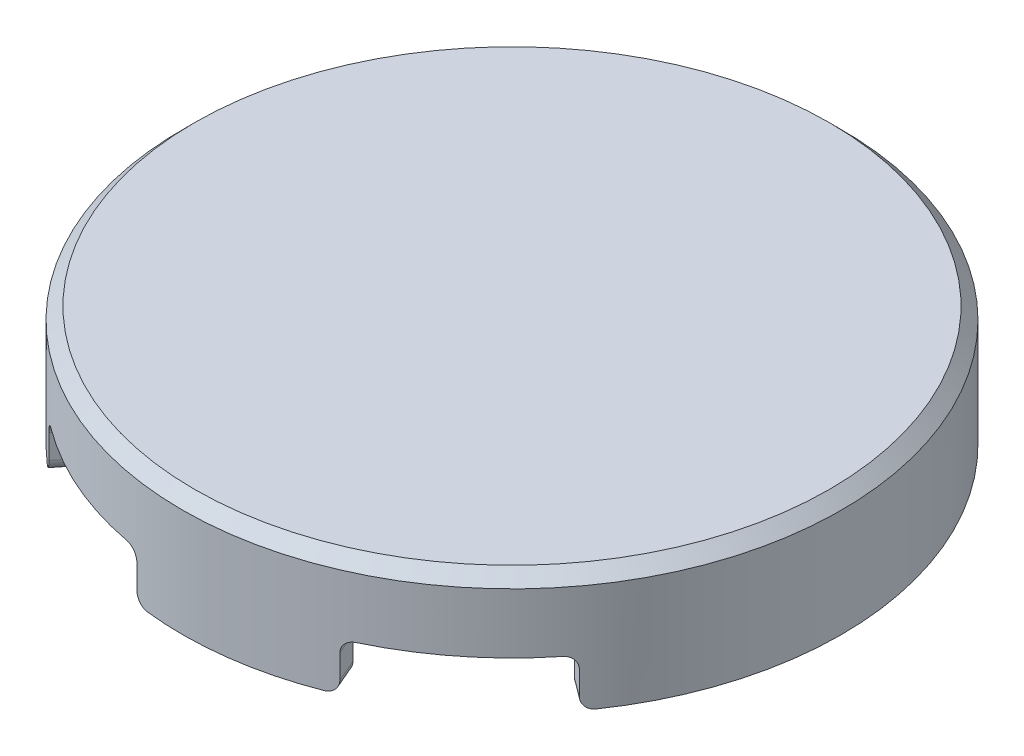
from build123d import *

# Parameters (mm, degrees)
SKETCH1_R           = 13.75
BOSS_EXTRUDE1_DEPTH = 5
SKETCH2_R           = 12.7
CUT_EXTRUDE1_DEPTH  = 3
CHAMFER1_SIZE       = 0.5
CUT_EXTRUDE2_DEPTH  = 2
FILLET1_R           = 0.5


with BuildPart() as part:
    # Sketch1 → Boss-Extrude1 (new body)
    with BuildSketch(Plane(origin=(0, 0, 0), x_dir=(1, 0, 0), z_dir=(0, 1, 0))):
        Circle(SKETCH1_R)
    extrude(amount=BOSS_EXTRUDE1_DEPTH)

    # Sketch2 → Cut-Extrude1 (cut)
    with BuildSketch(Plane.XZ):
        Circle(SKETCH2_R)
    extrude(amount=-CUT_EXTRUDE1_DEPTH, mode=Mode.SUBTRACT)

    # Chamfer1
    chamfer1_edges = [part.edges().sort_by_distance(p)[0] for p in [
        (-13.75, 5, 0),
    ]]
    chamfer(chamfer1_edges, length=CHAMFER1_SIZE)

    # Sketch4 → Cut-Extrude2 (cut)
    with BuildSketch(Plane.XZ):
        with BuildLine():
            Line((8.580294574, -10.744349446), (7.92507208, -9.923871852))
            ThreePointArc((7.92507208, -9.923871852), (5.08654476, -11.636883707), (1.901377822, -12.556861167))
            Line((1.901377822, -12.556861167), (2.05857835, -13.595026855))
            ThreePointArc((2.05857835, -13.595026855), (5.507085863, -12.598988265), (8.580294574, -10.744349446))
        make_face()
        with BuildLine():
            Line((-5.442522653, -12.627012599), (-5.026911832, -11.662768001))
            ThreePointArc((-5.026911832, -11.662768001), (-7.874170442, -9.964308298), (-10.184817349, -7.586797451))
            Line((-10.184817349, -7.586797451), (-11.026869177, -8.214052358))
            ThreePointArc((-11.026869177, -8.214052358), (-8.525184534, -10.788129062), (-5.442522653, -12.627012599))
        make_face()
        with BuildLine():
            Line((-8.580294574, 10.744349446), (-7.92507208, 9.923871852))
            ThreePointArc((-7.92507208, 9.923871852), (-5.08654476, 11.636883707), (-1.901377822, 12.556861167))
            Line((-1.901377822, 12.556861167), (-2.05857835, 13.595026855))
            ThreePointArc((-2.05857835, 13.595026855), (-5.507085863, 12.598988265), (-8.580294574, 10.744349446))
        make_face()
        with BuildLine():
            Line((5.442522653, 12.627012599), (5.026911832, 11.662768001))
            ThreePointArc((5.026911832, 11.662768001), (7.874170442, 9.964308298), (10.184817349, 7.586797451))
            Line((10.184817349, 7.586797451), (11.026869177, 8.214052358))
            ThreePointArc((11.026869177, 8.214052358), (8.525184534, 10.788129062), (5.442522653, 12.627012599))
        make_face()
    extrude(amount=-CUT_EXTRUDE2_DEPTH, mode=Mode.SUBTRACT)

    # Fillet1
    fillet1_edges = [part.edges().sort_by_distance(p)[0] for p in [
        (5.234717242, 2, 12.1448903),
        (5.234717242, 0, 12.1448903),
        (10.605843263, 0, 7.900424905),
        (10.605843263, 2, 7.900424905),
        (-1.979978086, 2, 13.075944011),
        (-1.979978086, 0, 13.075944011),
        (-8.252683327, 2, 10.334110649),
        (-8.252683327, 0, 10.334110649),
        (-10.605843263, 0, -7.900424905),
        (-10.605843263, 2, -7.900424905),
        (-5.234717242, 2, -12.1448903),
        (-5.234717242, 0, -12.1448903),
        (1.979978086, 0, -13.075944011),
        (1.979978086, 2, -13.075944011),
        (8.252683327, 0, -10.334110649),
        (8.252683327, 2, -10.334110649),
    ]]
    fillet(fillet1_edges, radius=FILLET1_R)


solid = part.part
